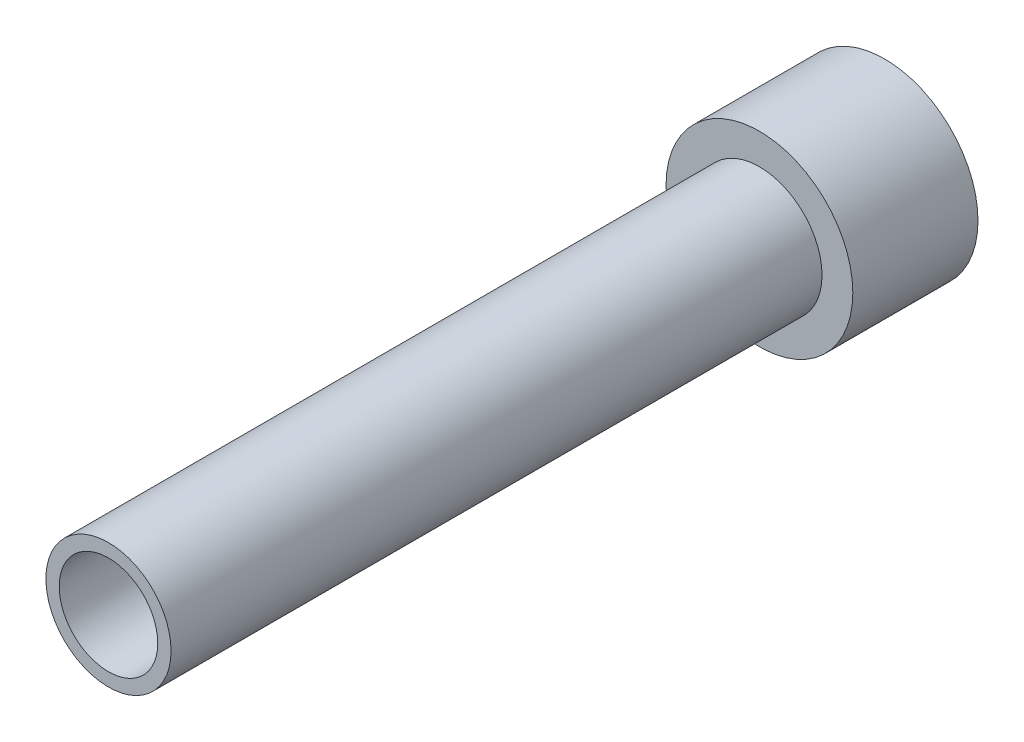
from build123d import *

# Parameters (mm, degrees)
SKETCH1_R                 = 4.7371
SKETCH1_R_2               = 2.5
BOSS_EXTRUDE1_DEPTH       = 6.35
SKETCH2_R                 = 3.175
SKETCH2_R_2               = 2.5
BOSS_EXTRUDE2_DEPTH       = 33.02
F_4_40_TAPPED_HOLE1_D     = 2.2606
F_4_40_TAPPED_HOLE1_DEPTH = 4.7361
F_4_40_TAPPED_HOLE1_TIP   = 0.679152758


with BuildPart() as part:
    # Sketch1 → Boss-Extrude1 (new body)
    with BuildSketch(Plane.XY):
        Circle(SKETCH1_R)
        Circle(SKETCH1_R_2, mode=Mode.SUBTRACT)
    extrude(amount=BOSS_EXTRUDE1_DEPTH)

    # Sketch2 → Boss-Extrude2 (add)
    with BuildSketch(Plane.XY.offset(6.35)):
        Circle(SKETCH2_R)
        Circle(SKETCH2_R_2, mode=Mode.SUBTRACT)
    extrude(amount=BOSS_EXTRUDE2_DEPTH)

    # #4-40 Tapped Hole1
    with Locations(Plane.ZY.offset(4.7371)):
        with Locations((3.191608174, 0)):
            Hole(F_4_40_TAPPED_HOLE1_D / 2, depth=F_4_40_TAPPED_HOLE1_DEPTH)
            with Locations((0, 0, -(F_4_40_TAPPED_HOLE1_DEPTH + F_4_40_TAPPED_HOLE1_TIP / 2))):  # 118° drill point
                Cone(0, F_4_40_TAPPED_HOLE1_D / 2, F_4_40_TAPPED_HOLE1_TIP, mode=Mode.SUBTRACT)


solid = part.part
